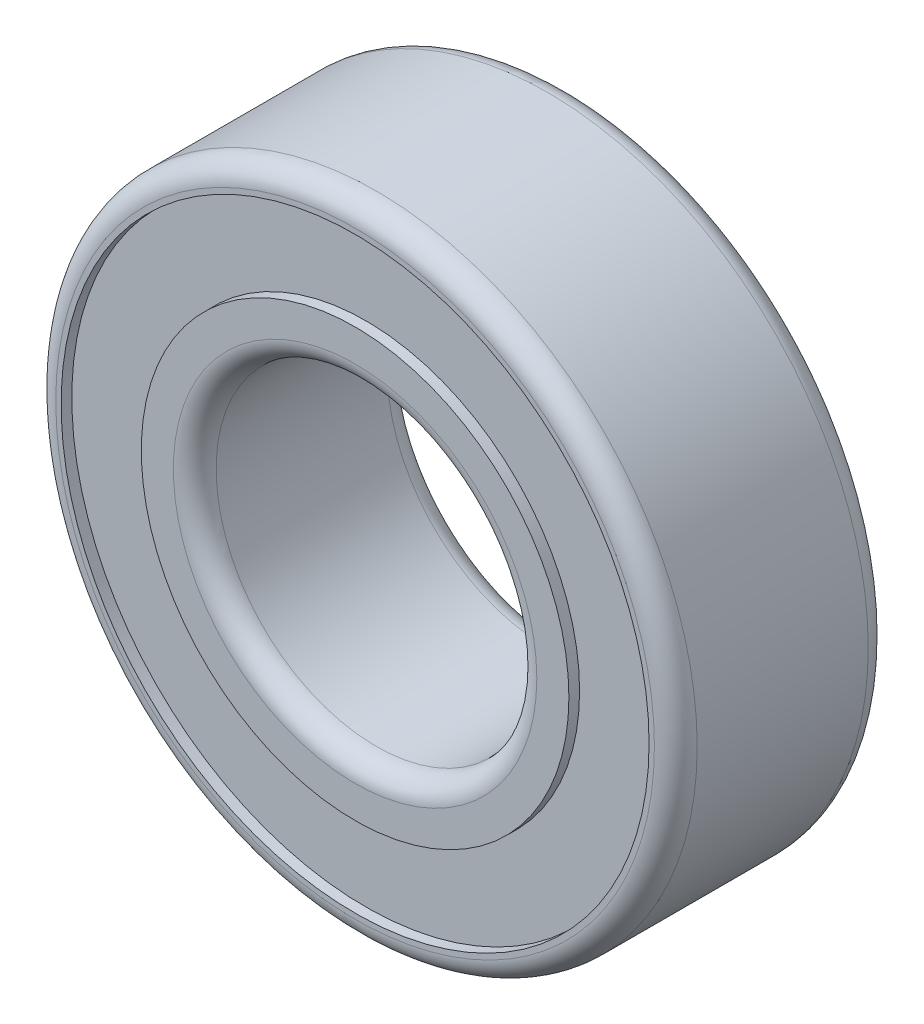
from build123d import *

# Parameters (mm, degrees)
SKETCH1_R           = 6
SKETCH1_R_2         = 3
BOSS_EXTRUDE1_DEPTH = 2
SKETCH2_R           = 5.5
SKETCH2_R_2         = 4
CUT_EXTRUDE1_DEPTH  = 0.2
FILLET1_R           = 0.4


with BuildPart() as part:
    # Sketch1 → Boss-Extrude1 (new body, symmetric)
    with BuildSketch(Plane.XY):
        Circle(SKETCH1_R)
        Circle(SKETCH1_R_2, mode=Mode.SUBTRACT)
    extrude(amount=BOSS_EXTRUDE1_DEPTH, both=True)

    # Sketch2 → Cut-Extrude1 (cut)
    with BuildSketch(Plane.XY.offset(2)):
        Circle(SKETCH2_R)
        Circle(SKETCH2_R_2, mode=Mode.SUBTRACT)
    cut_extrude1 = extrude(amount=-CUT_EXTRUDE1_DEPTH, mode=Mode.SUBTRACT)

    # Mirror1: Cut-Extrude1 across plane
    add(cut_extrude1.mirror(Plane.XY), mode=Mode.SUBTRACT)

    # Fillet1
    fillet1_edges = [part.edges().sort_by_distance(p)[0] for p in [
        (-6, 0, -2),
        (-6, 0, 2),
        (-3, 0, -2),
        (-3, 0, 2),
    ]]
    fillet(fillet1_edges, radius=FILLET1_R)


solid = part.part
